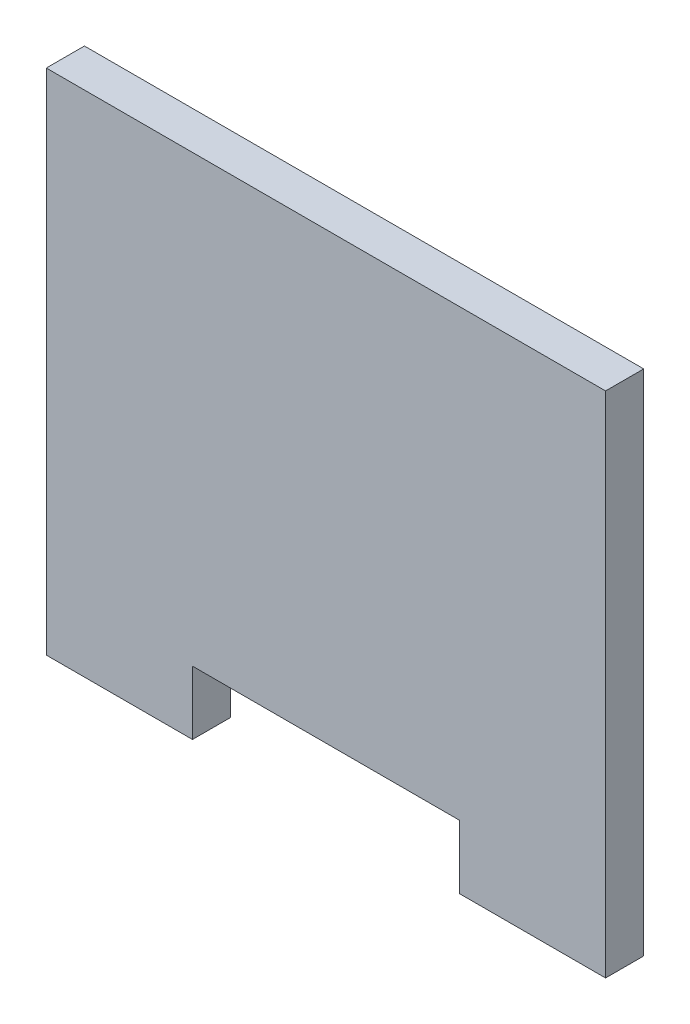
from build123d import *

# Parameters (mm, degrees)
EXTRUDE_1_DEPTH = 3


with BuildPart() as part:
    # 草图1 → 凸台-拉伸1 (new body)
    with BuildSketch(Plane.XY):
        Polygon((-22.694820717, 30.565946334), (21.305179283, 30.565946334), (21.305179283, -9.434053666), (9.805179283, -9.434053666), (9.805179283, -4.434053666), (-11.194820717, -4.434053666), (-11.194820717, -9.434053666), (-22.694820717, -9.434053666), align=None)
    extrude(amount=EXTRUDE_1_DEPTH)


solid = part.part
